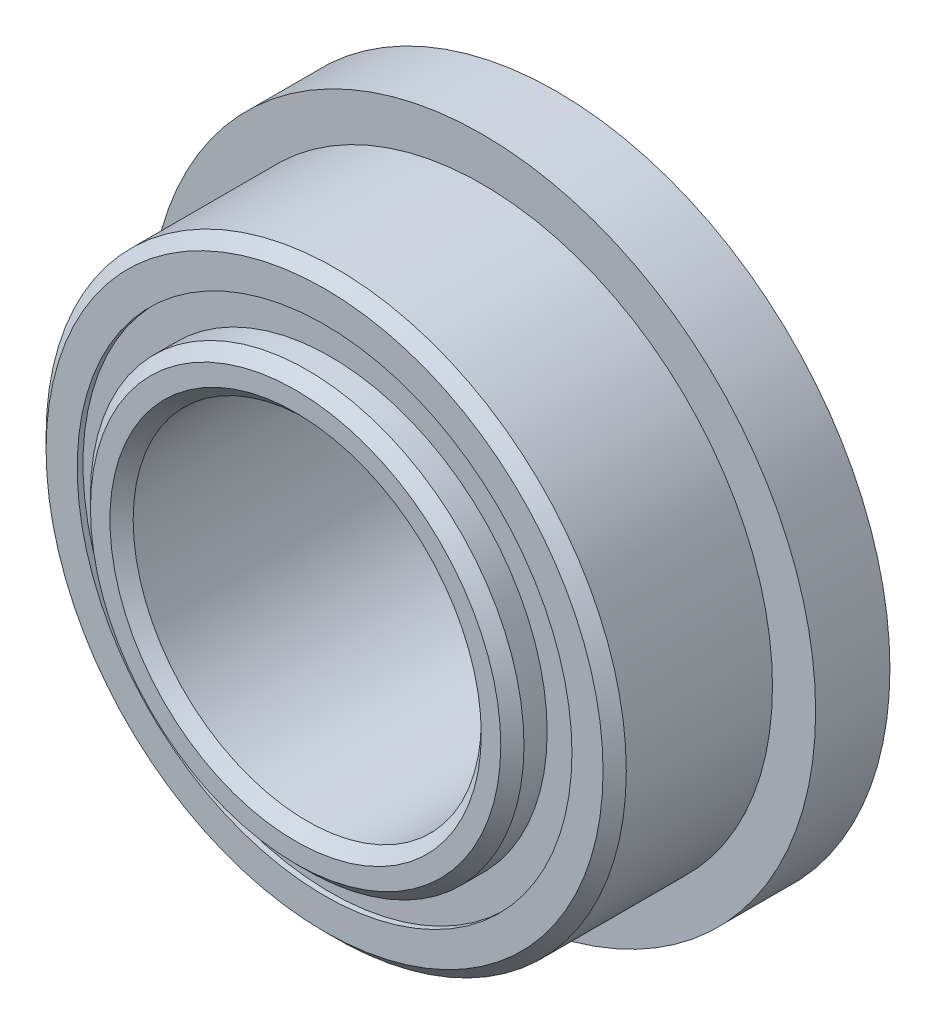
from build123d import *

# Parameters (mm, degrees)
CIRPATTERN1_COUNT = 10
SKETCH5_W         = 0.772168375
SKETCH5_H         = 0.418681318
SKETCH6_W         = 1.016
SKETCH6_H         = 1.174959341


with BuildPart() as part:
    # Sketch1 → Revolve1 (revolve)
    with BuildSketch(Plane(origin=(0, 0, 0), x_dir=(0, 0, -1), z_dir=(1, 0, 0))):
        with BuildLine():
            Line((1.42875, 3.96875), (-1.42875, 3.96875))
            Line((-1.42875, 3.96875), (-1.5875, 3.81))
            Line((-1.5875, 3.81), (-1.5875, 3.384340659))
            Line((-1.5875, 3.384340659), (-0.705555556, 3.384340659))
            ThreePointArc((-0.705555556, 3.384340659), (0, 3.910956625), (0.705555556, 3.384340659))
            Line((0.705555556, 3.384340659), (1.5875, 3.384340659))
            Line((1.5875, 3.384340659), (1.5875, 3.81))
            Line((1.5875, 3.81), (1.42875, 3.96875))
        make_face()
    revolve(axis=Axis((0, 0, 1.5875), (0, 0, -1)))

    # Sketch6 → Revolve6 (revolve)
    with BuildSketch(Plane(origin=(0, 0, 0), x_dir=(0, 0, -1), z_dir=(1, 0, 0))):
        with Locations((1.0795, 3.97182033)):
            Rectangle(SKETCH6_W, SKETCH6_H)
    revolve(axis=Axis((0, 0, -1.5875), (0, 0, 1)))


with BuildPart() as body_2:
    # Sketch3 → Revolve3 (revolve)
    with BuildSketch(Plane(origin=(0, 0, 0), x_dir=(0, 0, -1), z_dir=(1, 0, 0))):
        with BuildLine():
            Line((-1.98374, 2.54), (-1.98374, 2.806909341))
            Line((-1.98374, 2.806909341), (-1.82499, 2.965659341))
            Line((-1.82499, 2.965659341), (-0.705555556, 2.965659341))
            ThreePointArc((-0.705555556, 2.965659341), (0, 2.439043375), (0.705555556, 2.965659341))
            Line((0.705555556, 2.965659341), (1.82499, 2.965659341))
            Line((1.82499, 2.965659341), (1.98374, 2.806909341))
            Line((1.98374, 2.806909341), (1.98374, 2.54))
            Line((1.98374, 2.54), (1.82499, 2.38125))
            Line((1.82499, 2.38125), (-1.82499, 2.38125))
            Line((-1.82499, 2.38125), (-1.98374, 2.54))
        make_face()
    revolve(axis=Axis((0, 0, 1.5875), (0, 0, -1)))


with BuildPart() as body_3:
    # Sketch4 → Revolve4 (revolve)
    with BuildSketch(Plane(origin=(0, 0, 0), x_dir=(0, 0, -1), z_dir=(1, 0, 0))):
        with BuildLine():
            Line((-0.735956625, 3.175), (0.735956625, 3.175))
            ThreePointArc((0.735956625, 3.175), (0, 3.910956625), (-0.735956625, 3.175))
        make_face()
    revolve(axis=Axis((0, 3.175, 0.735956625), (0, 0, -1)))


with BuildPart() as cirpattern1_1:
    # CirPattern1: pattern copy
    add(body_3.part.rotate(Axis((0, 0, -1.5875), (0, 0, 1)), 1 * 360 / CIRPATTERN1_COUNT))


with BuildPart() as cirpattern1_2:
    # CirPattern1: pattern copy
    add(body_3.part.rotate(Axis((0, 0, -1.5875), (0, 0, 1)), 2 * 360 / CIRPATTERN1_COUNT))


with BuildPart() as cirpattern1_3:
    # CirPattern1: pattern copy
    add(body_3.part.rotate(Axis((0, 0, -1.5875), (0, 0, 1)), 3 * 360 / CIRPATTERN1_COUNT))


with BuildPart() as cirpattern1_4:
    # CirPattern1: pattern copy
    add(body_3.part.rotate(Axis((0, 0, -1.5875), (0, 0, 1)), 4 * 360 / CIRPATTERN1_COUNT))


with BuildPart() as cirpattern1_5:
    # CirPattern1: pattern copy
    add(body_3.part.rotate(Axis((0, 0, -1.5875), (0, 0, 1)), 5 * 360 / CIRPATTERN1_COUNT))


with BuildPart() as cirpattern1_6:
    # CirPattern1: pattern copy
    add(body_3.part.rotate(Axis((0, 0, -1.5875), (0, 0, 1)), 6 * 360 / CIRPATTERN1_COUNT))


with BuildPart() as cirpattern1_7:
    # CirPattern1: pattern copy
    add(body_3.part.rotate(Axis((0, 0, -1.5875), (0, 0, 1)), 7 * 360 / CIRPATTERN1_COUNT))


with BuildPart() as cirpattern1_8:
    # CirPattern1: pattern copy
    add(body_3.part.rotate(Axis((0, 0, -1.5875), (0, 0, 1)), 8 * 360 / CIRPATTERN1_COUNT))


with BuildPart() as cirpattern1_9:
    # CirPattern1: pattern copy
    add(body_3.part.rotate(Axis((0, 0, -1.5875), (0, 0, 1)), 9 * 360 / CIRPATTERN1_COUNT))


with BuildPart() as body_13:
    # Sketch5 → Revolve5 (revolve)
    with BuildSketch(Plane(origin=(0, 0, 0), x_dir=(0, 0, -1), z_dir=(1, 0, 0))):
        with Locations((-1.122040813, 3.175)):
            Rectangle(SKETCH5_W, SKETCH5_H)
        with Locations((1.122040813, 3.175)):
            Rectangle(SKETCH5_W, SKETCH5_H)
    revolve(axis=Axis((0, 0, 1.5875), (0, 0, -1)))


solid = Compound([part.part, body_2.part, body_3.part, cirpattern1_1.part, cirpattern1_2.part, cirpattern1_3.part, cirpattern1_4.part, cirpattern1_5.part, cirpattern1_6.part, cirpattern1_7.part, cirpattern1_8.part, cirpattern1_9.part, body_13.part])
